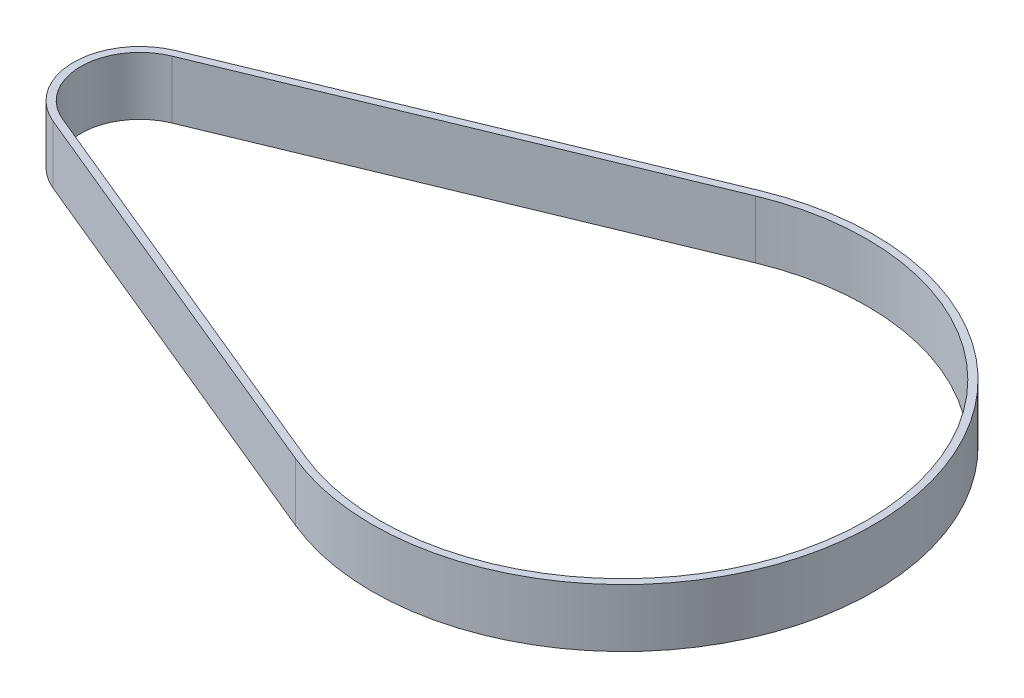
from build123d import *

# Parameters (mm, degrees)
BOSS_EXTRUDE1_DEPTH = 6


with BuildPart() as part:
    # Sketch1 → Boss-Extrude1 (new body)
    with BuildSketch(Plane.XZ.offset(-7.628326304)):
        with BuildLine():
            Line((81.876098577, 72.144512579), (39.196222867, 54.502914987))
            ThreePointArc((39.196222867, 54.502914987), (34.956549827, 48.163081659), (39.196222867, 41.823248331))
            Line((39.196222867, 41.823248331), (81.876098577, 24.18165074))
            Line((81.876098577, 24.18165074), (81.923583987, 24.162022789))
            ThreePointArc((81.923583987, 24.162022789), (117.776549827, 48.163081659), (81.923583987, 72.164140529))
            Line((81.923583987, 72.164140529), (81.876098577, 72.144512579))
        make_face()
        with BuildLine():
            Line((82.186737097, 24.863925245), (39.481862188, 42.514347463))
            ThreePointArc((39.481862188, 42.514347463), (35.704351827, 48.163081659), (39.481862188, 53.811815856))
            Line((39.481862188, 53.811815856), (82.186737097, 71.462238074))
            ThreePointArc((82.186737097, 71.462238074), (117.027340827, 48.163081659), (82.186737097, 24.863925245))
        make_face(mode=Mode.SUBTRACT)
    extrude(amount=BOSS_EXTRUDE1_DEPTH)


solid = part.part
